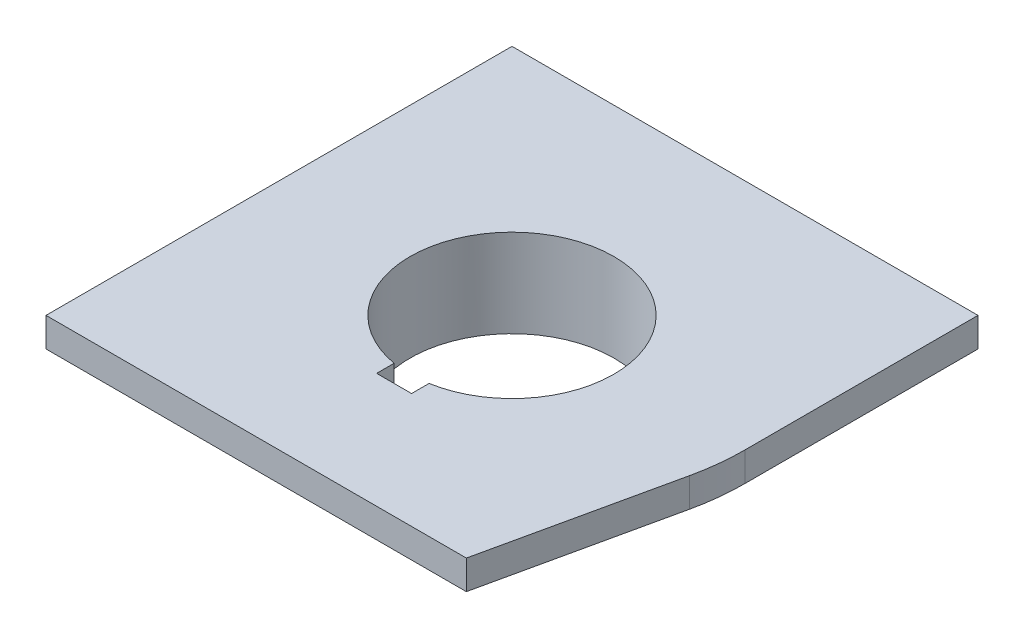
from build123d import *

# Parameters (mm, degrees)
SKETCH1_W           = 50.8
SKETCH1_H           = 50.8
SKETCH1_R           = 11.1125
BOSS_EXTRUDE1_DEPTH = 3.175
SKETCH2_R           = 11.1125
BOSS_EXTRUDE2_DEPTH = 3.2385
SKETCH3_R           = 11.1125
BOSS_EXTRUDE3_DEPTH = 3.175
SKETCH4_W           = 3.81
SKETCH4_H           = 1.905
CUT_EXTRUDE1_DEPTH  = 1.905
CUT_EXTRUDE2_DEPTH  = 4.175


with BuildPart() as part:
    # Sketch1 → Boss-Extrude1 (new body)
    with BuildSketch(Plane(origin=(0, 0, 0), x_dir=(1, 0, 0), z_dir=(0, 1, 0))):
        Rectangle(SKETCH1_W, SKETCH1_H)
        Circle(SKETCH1_R, mode=Mode.SUBTRACT)
    extrude(amount=BOSS_EXTRUDE1_DEPTH)

    # Sketch2 → Boss-Extrude2 (add)
    with BuildSketch(Plane.XZ):
        with BuildLine():
            ThreePointArc((-14.076948351, 2.368425674), (-14.196601152, -1.492122907), (-13.276909868, -5.243432024))
            ThreePointArc((-13.276909868, -5.243432024), (-13.179807483, -6.577553377), (-13.860975695, -7.72877817))
            ThreePointArc((-13.860975695, -7.72877817), (-14.480846101, -8.94534234), (-14.127459264, -10.264199968))
            ThreePointArc((-14.127459264, -10.264199968), (-12.982353661, -11.007840242), (-11.63378189, -10.794247457))
            ThreePointArc((-11.63378189, -10.794247457), (-10.328409495, -10.502166015), (-9.089590976, -11.006782042))
            ThreePointArc((-9.089590976, -11.006782042), (-5.806084233, -13.040678699), (-2.097509598, -14.119857242))
            ThreePointArc((-2.097509598, -14.119857242), (-0.893575422, -14.702824786), (-0.237169612, -15.868346158))
            ThreePointArc((-0.237169612, -15.868346158), (0.506470662, -17.013451761), (1.82532829, -17.366838598))
            ThreePointArc((1.82532829, -17.366838598), (3.04189246, -16.746968192), (3.531201567, -15.472274387))
            ThreePointArc((3.531201567, -15.472274387), (3.930937816, -14.195748011), (4.987357374, -13.375207717))
            ThreePointArc((4.987357374, -13.375207717), (8.390516919, -11.548555791), (11.17940027, -8.876425218))
            ThreePointArc((11.17940027, -8.876425218), (12.286232061, -8.125271409), (13.623806083, -8.139567988))
            ThreePointArc((13.623806083, -8.139567988), (14.987316762, -8.068109421), (15.952787554, -7.10263863))
            ThreePointArc((15.952787554, -7.10263863), (16.024246121, -5.73912795), (15.164983457, -4.67802693))
            ThreePointArc((15.164983457, -4.67802693), (14.259347311, -3.693581996), (14.076948351, -2.368425674))
            ThreePointArc((14.076948351, -2.368425674), (14.196601152, 1.492122907), (13.276909868, 5.243432024))
            ThreePointArc((13.276909868, 5.243432024), (13.179807483, 6.577553377), (13.860975695, 7.72877817))
            ThreePointArc((13.860975695, 7.72877817), (14.480846101, 8.94534234), (14.127459264, 10.264199968))
            ThreePointArc((14.127459264, 10.264199968), (12.982353661, 11.007840242), (11.63378189, 10.794247457))
            ThreePointArc((11.63378189, 10.794247457), (10.328409495, 10.502166015), (9.089590976, 11.006782042))
            ThreePointArc((9.089590976, 11.006782042), (5.806084233, 13.040678699), (2.097509598, 14.119857242))
            ThreePointArc((2.097509598, 14.119857242), (0.893575422, 14.702824786), (0.237169612, 15.868346158))
            ThreePointArc((0.237169612, 15.868346158), (-0.506470662, 17.013451761), (-1.82532829, 17.366838598))
            ThreePointArc((-1.82532829, 17.366838598), (-3.04189246, 16.746968192), (-3.531201567, 15.472274387))
            ThreePointArc((-3.531201567, 15.472274387), (-3.930937816, 14.195748011), (-4.987357374, 13.375207717))
            ThreePointArc((-4.987357374, 13.375207717), (-8.390516919, 11.548555791), (-11.17940027, 8.876425218))
            ThreePointArc((-11.17940027, 8.876425218), (-12.286232061, 8.125271409), (-13.623806083, 8.139567988))
            ThreePointArc((-13.623806083, 8.139567988), (-14.987316762, 8.068109421), (-15.952787554, 7.10263863))
            ThreePointArc((-15.952787554, 7.10263863), (-16.024246121, 5.73912795), (-15.164983457, 4.67802693))
            ThreePointArc((-15.164983457, 4.67802693), (-14.259347311, 3.693581996), (-14.076948351, 2.368425674))
        make_face()
        Circle(SKETCH2_R, mode=Mode.SUBTRACT)
    extrude(amount=BOSS_EXTRUDE2_DEPTH)

    # Sketch3 → Boss-Extrude3 (add)
    with BuildSketch(Plane.XZ.offset(3.2385)):
        with BuildLine():
            ThreePointArc((-13.623806083, 8.139567988), (-12.286232061, 8.125271409), (-11.17940027, 8.876425218))
            ThreePointArc((-11.17940027, 8.876425218), (-9.625048397, 10.541743612), (-7.82558077, 11.938601285))
            ThreePointArc((-7.82558077, 11.938601285), (-6.977108558, 12.97272099), (-6.869996245, 14.30607601))
            ThreePointArc((-6.869996245, 14.30607601), (-6.675129359, 15.657480685), (-5.626048811, 16.531378679))
            ThreePointArc((-5.626048811, 16.531378679), (-3.749033675, 17.05531157), (-1.82532829, 17.366838598))
            ThreePointArc((-1.82532829, 17.366838598), (-0.506470662, 17.013451761), (0.237169612, 15.868346158))
            ThreePointArc((0.237169612, 15.868346158), (0.893575422, 14.702824786), (2.097509598, 14.119857242))
            ThreePointArc((2.097509598, 14.119857242), (4.31689357, 13.606408231), (6.426341614, 12.746452389))
            ThreePointArc((6.426341614, 12.746452389), (7.746151654, 12.528713751), (8.954427131, 13.102629278))
            ThreePointArc((8.954427131, 13.102629278), (10.222211353, 13.609571941), (11.50356949, 13.137990533))
            ThreePointArc((11.50356949, 13.137990533), (12.895816252, 11.774414187), (14.127459264, 10.264199968))
            ThreePointArc((14.127459264, 10.264199968), (14.480846101, 8.94534234), (13.860975695, 7.72877817))
            ThreePointArc((13.860975695, 7.72877817), (13.179807483, 6.577553377), (13.276909868, 5.243432024))
            ThreePointArc((13.276909868, 5.243432024), (13.941941967, 3.064664618), (14.251922384, 0.807851103))
            ThreePointArc((14.251922384, 0.807851103), (14.723260212, -0.444007239), (15.824423376, -1.203446733))
            ThreePointArc((15.824423376, -1.203446733), (16.897340712, -2.047908744), (17.129618301, -3.393388146))
            ThreePointArc((17.129618301, -3.393388146), (16.644849927, -5.280897383), (15.952787554, -7.10263863))
            ThreePointArc((15.952787554, -7.10263863), (14.987316762, -8.068109421), (13.623806083, -8.139567988))
            ThreePointArc((13.623806083, -8.139567988), (12.286232061, -8.125271409), (11.17940027, -8.876425218))
            ThreePointArc((11.17940027, -8.876425218), (9.625048397, -10.541743612), (7.82558077, -11.938601285))
            ThreePointArc((7.82558077, -11.938601285), (6.977108558, -12.97272099), (6.869996245, -14.30607601))
            ThreePointArc((6.869996245, -14.30607601), (6.675129359, -15.657480685), (5.626048811, -16.531378679))
            ThreePointArc((5.626048811, -16.531378679), (3.749033675, -17.05531157), (1.82532829, -17.366838598))
            ThreePointArc((1.82532829, -17.366838598), (0.506470662, -17.013451761), (-0.237169612, -15.868346158))
            ThreePointArc((-0.237169612, -15.868346158), (-0.893575422, -14.702824786), (-2.097509598, -14.119857242))
            ThreePointArc((-2.097509598, -14.119857242), (-4.31689357, -13.606408231), (-6.426341614, -12.746452389))
            ThreePointArc((-6.426341614, -12.746452389), (-7.746151654, -12.528713751), (-8.954427131, -13.102629278))
            ThreePointArc((-8.954427131, -13.102629278), (-10.222211353, -13.609571941), (-11.50356949, -13.137990533))
            ThreePointArc((-11.50356949, -13.137990533), (-12.895816252, -11.774414187), (-14.127459264, -10.264199968))
            ThreePointArc((-14.127459264, -10.264199968), (-14.480846101, -8.94534234), (-13.860975695, -7.72877817))
            ThreePointArc((-13.860975695, -7.72877817), (-13.179807483, -6.577553377), (-13.276909868, -5.243432024))
            ThreePointArc((-13.276909868, -5.243432024), (-13.941941967, -3.064664618), (-14.251922384, -0.807851103))
            ThreePointArc((-14.251922384, -0.807851103), (-14.723260212, 0.444007239), (-15.824423376, 1.203446733))
            ThreePointArc((-15.824423376, 1.203446733), (-16.897340712, 2.047908744), (-17.129618301, 3.393388146))
            ThreePointArc((-17.129618301, 3.393388146), (-16.644849927, 5.280897383), (-15.952787554, 7.10263863))
            ThreePointArc((-15.952787554, 7.10263863), (-14.987316762, 8.068109421), (-13.623806083, 8.139567988))
        make_face()
        Circle(SKETCH3_R, mode=Mode.SUBTRACT)
    extrude(amount=BOSS_EXTRUDE3_DEPTH)

    # Sketch4 → Cut-Extrude1 (cut)
    with BuildSketch(Plane(origin=(0, 3.175, 0), x_dir=(1, 0, 0), z_dir=(0, 1, 0))):
        with Locations((0, -11.900496677)):
            Rectangle(SKETCH4_W, SKETCH4_H)
    extrude(amount=-CUT_EXTRUDE1_DEPTH, mode=Mode.SUBTRACT)

    # Sketch5 → Cut-Extrude2 (cut, through all)
    with BuildSketch(Plane.XZ):
        with BuildLine():
            Line((20.423083051, 25.4), (24.80772592, 5.45313989))
            ThreePointArc((24.80772592, 5.45313989), (25.251497365, 2.74260475), (25.4, 0))
            Line((25.4, 0), (25.4, 25.4))
            Line((25.4, 25.4), (20.423083051, 25.4))
        make_face()
    extrude(amount=-CUT_EXTRUDE2_DEPTH, mode=Mode.SUBTRACT)


solid = part.part
